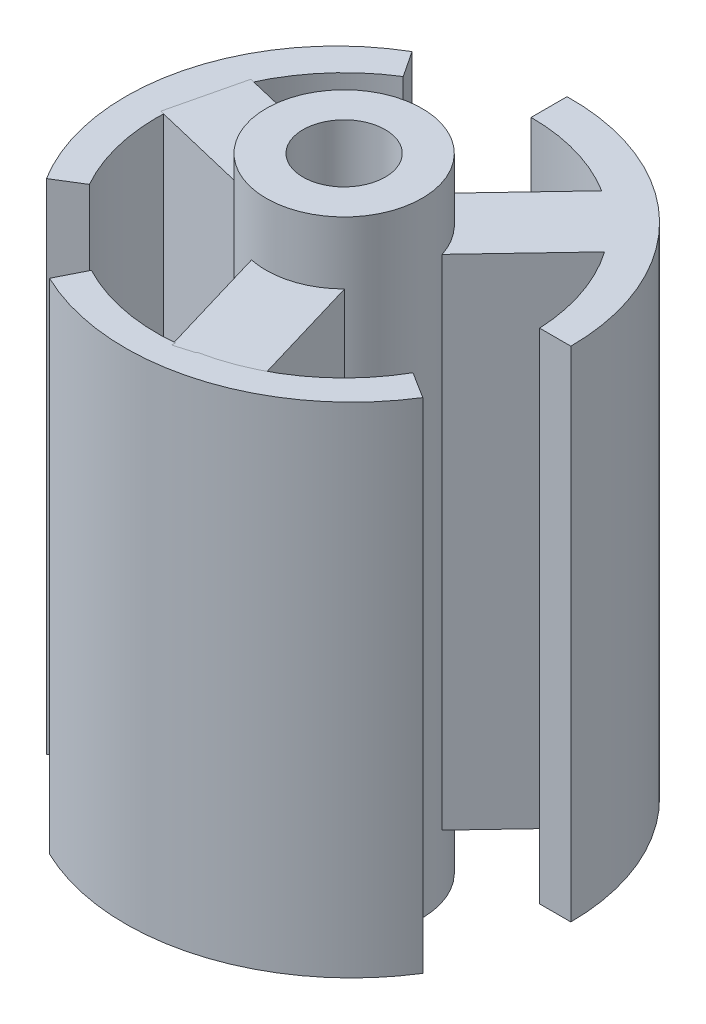
from build123d import *

# Parameters (mm, degrees)
BOSS_EXTRUDE6_DEPTH   = 40
BOSS_EXTRUDE6_2_DEPTH = 40
BOSS_EXTRUDE6_3_DEPTH = 40
SKETCH12_R            = 15
CUT_EXTRUDE9_DEPTH    = 40
BOSS_EXTRUDE8_DEPTH   = 40
SKETCH18_R            = 6.25
BOSS_EXTRUDE9_DEPTH   = 45
SKETCH18_2_R          = 6.25
BOSS_EXTRUDE10_DEPTH  = 5
SKETCH19_R            = 3.3
CUT_EXTRUDE10_DEPTH   = 50


with BuildPart() as part:
    # Sketch11 → Boss-Extrude6 (new body)
    with BuildSketch(Plane(origin=(0, 0, 0), x_dir=(1, 0, 0), z_dir=(0, 1, 0))):
        with BuildLine():
            ThreePointArc((-9.349413612, 14.793189822), (-17.216152438, 4.282475359), (-15.190534929, -8.688938287))
            Line((-15.190534929, -8.688938287), (0, 0.700234787))
            Line((0, 0.700234787), (-9.349413612, 14.793189822))
        make_face()
    extrude(amount=BOSS_EXTRUDE6_DEPTH)


with BuildPart() as body_2:
    # Sketch11 → Boss-Extrude6 2 (new body)
    with BuildSketch(Plane(origin=(0, 0, 0), x_dir=(1, 0, 0), z_dir=(0, 1, 0))):
        with BuildLine():
            Line((0, 17.881636961), (0, 0.700234787))
            Line((0, 0.700234787), (17.485984995, 0.700234787))
            ThreePointArc((17.485984995, 0.700234787), (12.345670366, 12.957480113), (0, 17.881636961))
        make_face()
    extrude(amount=BOSS_EXTRUDE6_2_DEPTH)


with BuildPart() as body_3:
    # Sketch11 → Boss-Extrude6 3 (new body)
    with BuildSketch(Plane(origin=(0, 0, 0), x_dir=(1, 0, 0), z_dir=(0, 1, 0))):
        with BuildLine():
            Line((15.120108753, -8.810920002), (0, 0.700234787))
            Line((0, 0.700234787), (-8.136571383, -15.49342461))
            ThreePointArc((-8.136571383, -15.49342461), (4.767573461, -16.592271542), (15.120108753, -8.810920002))
        make_face()
    extrude(amount=BOSS_EXTRUDE6_3_DEPTH)


with BuildPart() as cut_extrude9_tool:
    # Sketch12 → Cut-Extrude9 (new body)
    with BuildSketch(Plane(origin=(0, 0, 0), x_dir=(1, 0, 0), z_dir=(0, 1, 0))):
        Circle(SKETCH12_R)
    extrude(amount=CUT_EXTRUDE9_DEPTH)


with BuildPart() as part_1:
    add(part.part)

    # Cut-Extrude9: cut by cut_extrude9_tool
    add(cut_extrude9_tool.part, mode=Mode.SUBTRACT)


with BuildPart() as body_2_1:
    add(body_2.part)

    # Cut-Extrude9: cut by cut_extrude9_tool
    add(cut_extrude9_tool.part, mode=Mode.SUBTRACT)



with BuildPart() as body_3_1:
    add(body_3.part)

    # Cut-Extrude9: cut by cut_extrude9_tool
    add(cut_extrude9_tool.part, mode=Mode.SUBTRACT)


with BuildPart() as body_4:
    # Sketch17 → Boss-Extrude8 (new body)
    with BuildSketch(Plane(origin=(0, 0, 0), x_dir=(1, 0, 0), z_dir=(0, 1, 0))):
        Polygon((3.368966021, -0.806267914), (12.495130342, 8.824495324), (8.139929807, 12.951507354), (-0.986234515, 3.320744116), (-13.889802298, 6.408852638), (-15.286299289, 0.573632321), (-2.382731506, -2.514476202), (1.394671955, -15.233347962), (7.146369483, -13.525139675), align=None)
    extrude(amount=BOSS_EXTRUDE8_DEPTH)


with BuildPart() as body_2_2:
    add(body_2_1.part)

    add(body_4.part)  # Boss-Extrude9 merges body 4
    # Sketch18 → Boss-Extrude9 (add)
    with BuildSketch(Plane(origin=(0, 0, 0), x_dir=(1, 0, 0), z_dir=(0, 1, 0))):
        Circle(SKETCH18_R)
    extrude(amount=BOSS_EXTRUDE9_DEPTH)

    # Sketch18_2 → Boss-Extrude10 (add)
    with BuildSketch(Plane(origin=(0, 0, 0), x_dir=(1, 0, 0), z_dir=(0, 1, 0))):
        Circle(SKETCH18_2_R)
    extrude(amount=-BOSS_EXTRUDE10_DEPTH)

    # Sketch19 → Cut-Extrude10 (cut)
    with BuildSketch(Plane(origin=(0, -5, 0), x_dir=(-1, 0, 0), z_dir=(0, -1, 0))):
        Circle(SKETCH19_R)
    extrude(amount=-CUT_EXTRUDE10_DEPTH, mode=Mode.SUBTRACT)


solid = Compound([part_1.part, body_3_1.part, body_2_2.part])
